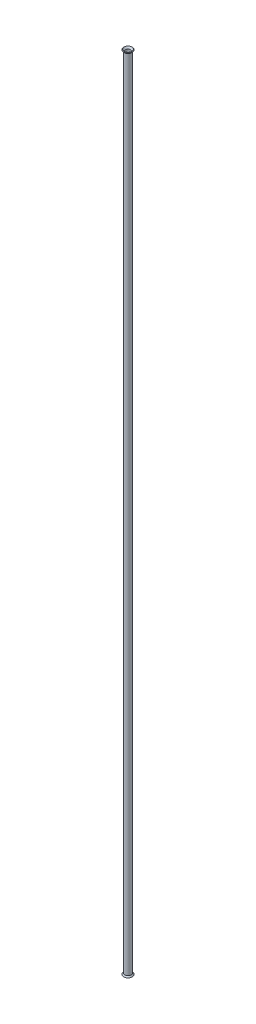
from build123d import *

# Parameters (mm, degrees)
SKETCH1_R           = 12.7
SKETCH1_R_2         = 9.525
BOSS_EXTRUDE1_DEPTH = 3093.72


with BuildPart() as part:
    # Sketch1 → Boss-Extrude1 (new body)
    with BuildSketch(Plane(origin=(0, 0, 0), x_dir=(1, 0, 0), z_dir=(0, 1, 0))):
        Circle(SKETCH1_R)
        Circle(SKETCH1_R_2, mode=Mode.SUBTRACT)
    extrude(amount=BOSS_EXTRUDE1_DEPTH)

    # Sketch2 → Revolve1 (revolve)
    with BuildSketch(Plane.XY):
        Polygon((12.7, 3093.72), (16.781701322, 3098.584382214), (14.918534839, 3100.147764522), (9.525, 3093.72), align=None)
    revolve1 = revolve(axis=Axis((0, 3248.406, 0), (0, -1, 0)))

    # Mirror1: Revolve1 across plane
    add(revolve1.mirror(Plane.ZX.offset(1546.86)))


solid = part.part
